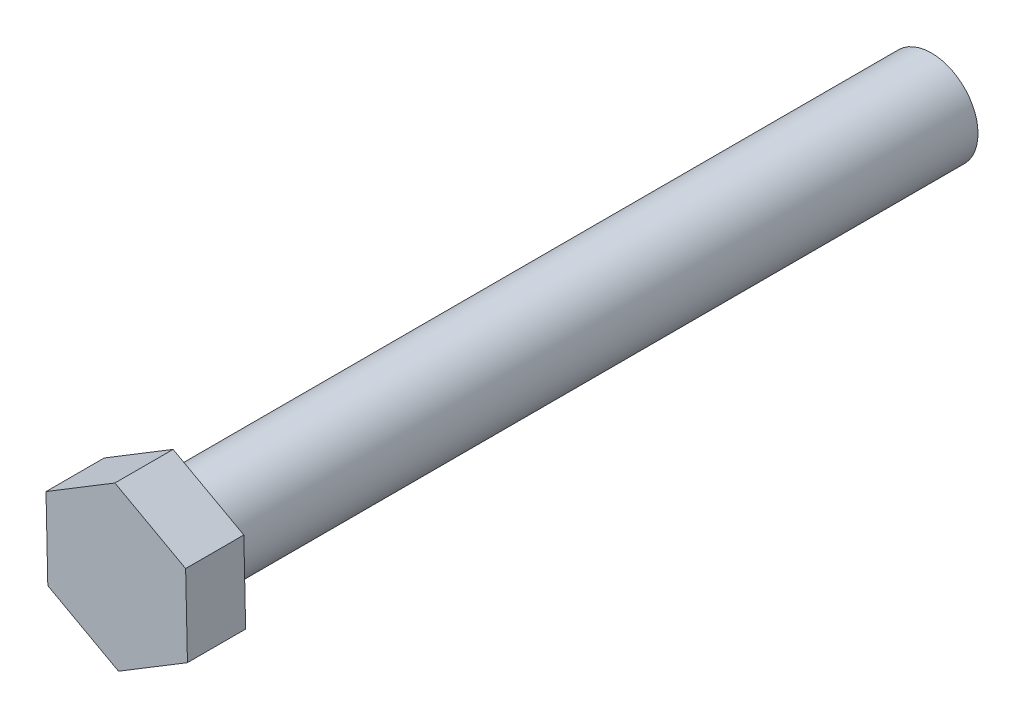
from build123d import *

# Parameters (mm, degrees)
SKETCH_1_R      = 4
EXTRUDE_1_DEPTH = 65
EXTRUDE_2_DEPTH = 5


with BuildPart() as part:
    # 草图1 → 凸台-拉伸1 (new body)
    with BuildSketch(Plane.XY):
        Circle(SKETCH_1_R)
    extrude(amount=EXTRUDE_1_DEPTH)

    # 草图2 → 凸台-拉伸2 (add)
    with BuildSketch(Plane.XY.offset(65)):
        Polygon((6.076377829, -3.32830775), (5.920587978, 3.598143688), (-0.155789852, 6.926451438), (-6.076377829, 3.32830775), (-5.920587978, -3.598143688), (0.155789852, -6.926451438), align=None)
    extrude(amount=EXTRUDE_2_DEPTH)


solid = part.part
